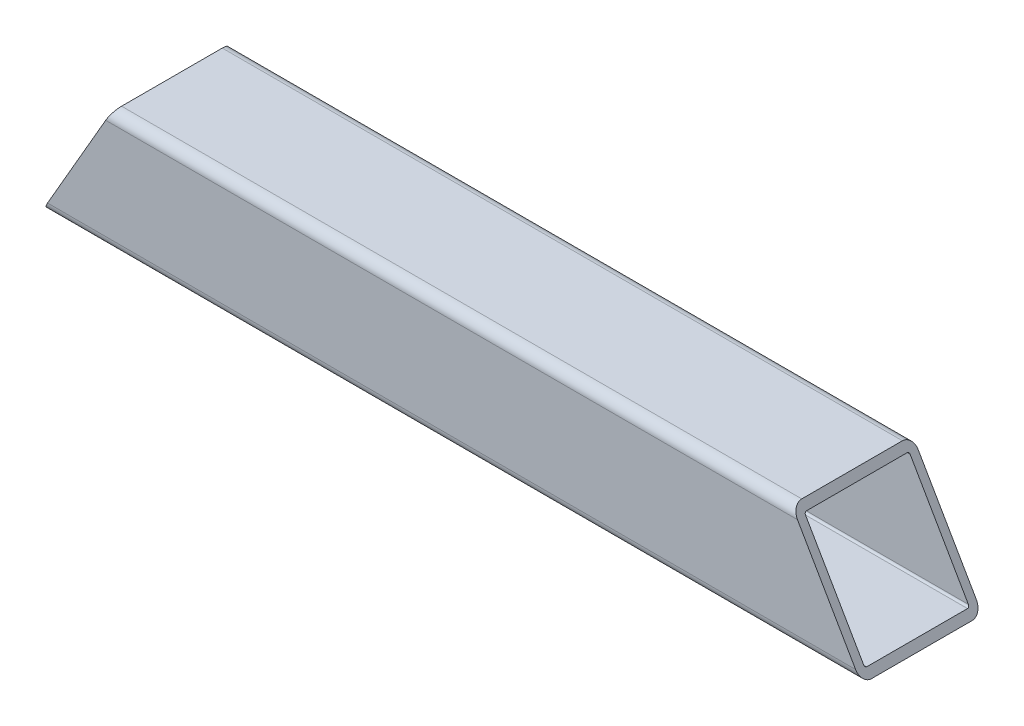
from build123d import *

# Parameters (mm, degrees)
EXTRUDE_THIN1_DEPTH     = 129.2225
CUT_EXTRUDE1_DEPTH      = 1
CUT_EXTRUDE1_DEPTH_BACK = 39.1
CUT_EXTRUDE2_DEPTH      = 1
CUT_EXTRUDE2_DEPTH_BACK = 39.1


with BuildPart() as part:
    # Sketch1 → Extrude-Thin1 (new body, symmetric)
    with BuildSketch(Plane(origin=(0, 0, 0), x_dir=(0, 0, -1), z_dir=(1, 0, 0))):
        with BuildLine():
            Line((-15.875, 19.05), (15.875, 19.05))
            ThreePointArc((15.875, 19.05), (18.12006403, 18.12006403), (19.05, 15.875))
            Line((19.05, 15.875), (19.05, -15.875))
            ThreePointArc((19.05, -15.875), (18.12006403, -18.12006403), (15.875, -19.05))
            Line((15.875, -19.05), (-15.875, -19.05))
            ThreePointArc((-15.875, -19.05), (-18.12006403, -18.12006403), (-19.05, -15.875))
            Line((-19.05, -15.875), (-19.05, 15.875))
            ThreePointArc((-19.05, 15.875), (-18.12006403, 18.12006403), (-15.875, 19.05))
        make_face()
        with BuildLine():
            Line((-15.875, 16.51), (15.875, 16.51))
            ThreePointArc((15.875, 16.51), (16.324012806, 16.324012806), (16.51, 15.875))
            Line((16.51, 15.875), (16.51, -15.875))
            ThreePointArc((16.51, -15.875), (16.324012806, -16.324012806), (15.875, -16.51))
            Line((15.875, -16.51), (-15.875, -16.51))
            ThreePointArc((-15.875, -16.51), (-16.324012806, -16.324012806), (-16.51, -15.875))
            Line((-16.51, -15.875), (-16.51, 15.875))
            ThreePointArc((-16.51, 15.875), (-16.324012806, 16.324012806), (-15.875, 16.51))
        make_face(mode=Mode.SUBTRACT)
    extrude(amount=EXTRUDE_THIN1_DEPTH, both=True)

    # Sketch2 → Cut-Extrude1 (cut, two sides)
    with BuildSketch(Plane.XY.offset(19.05)) as cut_extrude1_sk:
        Polygon((-395.460759114, -480.188191704), (-129.2225, -19.05), (-107.225454744, 19.05), (159.01280437, 480.188191704), (-763.263579039, 1012.664709933), (-1317.737142523, 52.288326524), align=None)
    extrude(amount=CUT_EXTRUDE1_DEPTH, mode=Mode.SUBTRACT)
    extrude(cut_extrude1_sk.sketch, amount=-CUT_EXTRUDE1_DEPTH_BACK, mode=Mode.SUBTRACT)

    # Sketch3 → Cut-Extrude2 (cut, two sides)
    with BuildSketch(Plane.XY.offset(19.05)) as cut_extrude2_sk:
        Polygon((395.460759114, -480.188191704), (129.2225, -19.05), (107.225454744, 19.05), (-159.01280437, 480.188191704), (763.263579039, 1012.664709933), (1317.737142523, 52.288326524), align=None)
    extrude(amount=CUT_EXTRUDE2_DEPTH, mode=Mode.SUBTRACT)
    extrude(cut_extrude2_sk.sketch, amount=-CUT_EXTRUDE2_DEPTH_BACK, mode=Mode.SUBTRACT)


solid = part.part
